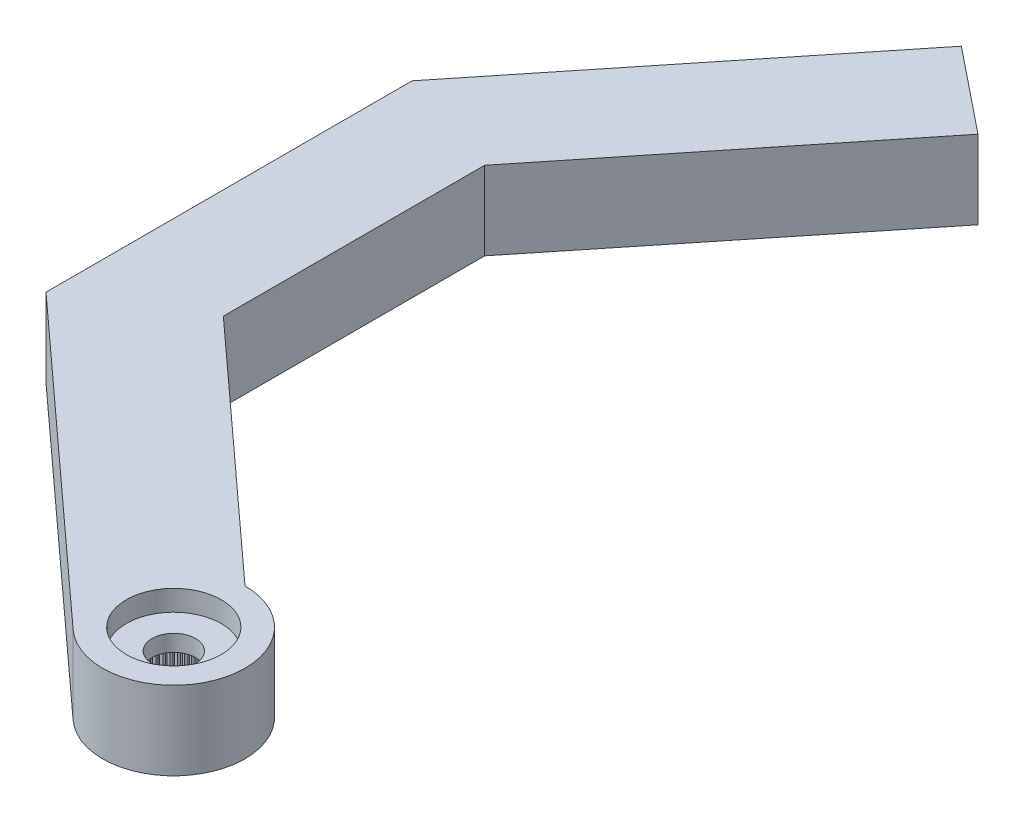
from build123d import *

# Parameters (mm, degrees)
RESSALTO_EXTRUS_O1_DEPTH = 1.4
ESBO_O2_R                = 3.45
RESSALTO_EXTRUS_O2_DEPTH = 2.4
FURO4_D                  = 1.2
PADR_O_LINEAR1_COUNT     = 6
PADR_O_LINEAR1_PITCH     = 2
FURO1_D                  = 4.95
FURO1_DEPTH              = 2
FURO2_D                  = 4.6
FURO2_DEPTH              = 1
FURO3_D                  = 2.1
RESSALTO_EXTRUS_O3_DEPTH = 2
PADR_OCIRCULAR1_COUNT    = 60
CUT_EXTRUDE1_DEPTH       = 10
BOSS_EXTRUDE1_DEPTH      = 3.8


with BuildPart() as part:
    # Esboço1 → Ressalto-extrusão1 (new body)
    with BuildSketch(Plane(origin=(0, 0, 0), x_dir=(1, 0, 0), z_dir=(0, 1, 0))):
        with BuildLine():
            Line((-14.159121967, 1.99702088), (-2.209072203, 2.65))
            ThreePointArc((-2.209072203, 2.65), (3.45, 0), (-2.209072203, -2.65))
            Line((-2.209072203, -2.65), (-14.159121967, -1.99702088))
            ThreePointArc((-14.159121967, -1.99702088), (-16.05, 0), (-14.159121967, 1.99702088))
        make_face()
    extrude(amount=-RESSALTO_EXTRUS_O1_DEPTH)

    # Esboço2 → Ressalto-extrusão2 (add)
    with BuildSketch(Plane.XZ.offset(1.4)):
        Circle(ESBO_O2_R)
    extrude(amount=RESSALTO_EXTRUS_O2_DEPTH)

    # Furo4 (through all)
    with Locations(Plane(origin=(0, 0, 0), x_dir=(1, 0, 0), z_dir=(0, 1, 0))):
        with Locations((-14.45, 0)):
            furo4 = Hole(FURO4_D / 2)

    # Padrão linear1: Furo4 ×6
    with Locations(*[(i * PADR_O_LINEAR1_PITCH, 0, 0) for i in range(1, PADR_O_LINEAR1_COUNT)]):
        add(furo4, mode=Mode.SUBTRACT)

    # Furo1
    with Locations(Plane(origin=(0, -3.8, 0), x_dir=(-1, 0, 0), z_dir=(0, -1, 0))):
        with Locations((0, 0)):
            Hole(FURO1_D / 2, depth=FURO1_DEPTH)

    # Furo2
    with Locations(Plane(origin=(0, 0, 0), x_dir=(1, 0, 0), z_dir=(0, 1, 0))):
        with Locations((0, 0)):
            Hole(FURO2_D / 2, depth=FURO2_DEPTH)

    # Furo3 (through all)
    with Locations(Plane(origin=(0, 0, 0), x_dir=(1, 0, 0), z_dir=(0, 1, 0))):
        with Locations((0, 0)):
            Hole(FURO3_D / 2)

    # Esboço11 → Ressalto-extrusão3 (add)
    with BuildSketch(Plane.XZ.offset(3.8)):
        with BuildLine():
            Line((-0.098056786, 2.473056786), (0, 2.375))
            Line((0, 2.375), (0.098056786, 2.473056786))
            ThreePointArc((0.098056786, 2.473056786), (0, 2.475), (-0.098056786, 2.473056786))
        make_face()
    ressalto_extrus_o3 = extrude(amount=-RESSALTO_EXTRUS_O3_DEPTH)

    # PadrãoCircular1: Ressalto-extrusão3 ×60 about axis
    padr_ocircular1_axis = Axis((0, 0, 0), (0, 1, 0))
    for i in range(1, PADR_OCIRCULAR1_COUNT):
        add(ressalto_extrus_o3.rotate(padr_ocircular1_axis, i * 360 / PADR_OCIRCULAR1_COUNT))

    # Sketch1 → Cut-Extrude1 (cut)
    with BuildSketch(Plane.XZ.offset(3.8)):
        with BuildLine():
            Line((0, 3.45), (-16.05, 3.45))
            Line((-16.05, 3.45), (-16.05, -3.45))
            Line((-16.05, -3.45), (0, -3.45))
            ThreePointArc((0, -3.45), (-3.45, 0), (0, 3.45))
        make_face()
    extrude(amount=-CUT_EXTRUDE1_DEPTH, mode=Mode.SUBTRACT)

    # Sketch2 → Boss-Extrude1 (add)
    with BuildSketch(Plane(origin=(0, 0, 0), x_dir=(1, 0, 0), z_dir=(0, 1, 0))):
        with BuildLine():
            Line((0, 3.45), (-11.841431407, 14.240980385))
            Line((-11.841431407, 14.240980385), (-11.841431407, 26.898431862))
            Line((-11.841431407, 26.898431862), (-1.20031972, 40.147481011))
            Line((-1.20031972, 40.147481011), (-5.293722372, 43.435139945))
            Line((-5.293722372, 43.435139945), (-17.141431407, 28.683779004))
            Line((-17.141431407, 28.683779004), (-17.141431407, 10.953171381))
            Line((-17.141431407, 10.953171381), (-2.323790008, -2.55))
            ThreePointArc((-2.323790008, -2.55), (-3.217141588, 1.245993579), (0, 3.45))
        make_face()
    extrude(amount=-BOSS_EXTRUDE1_DEPTH)


solid = part.part
